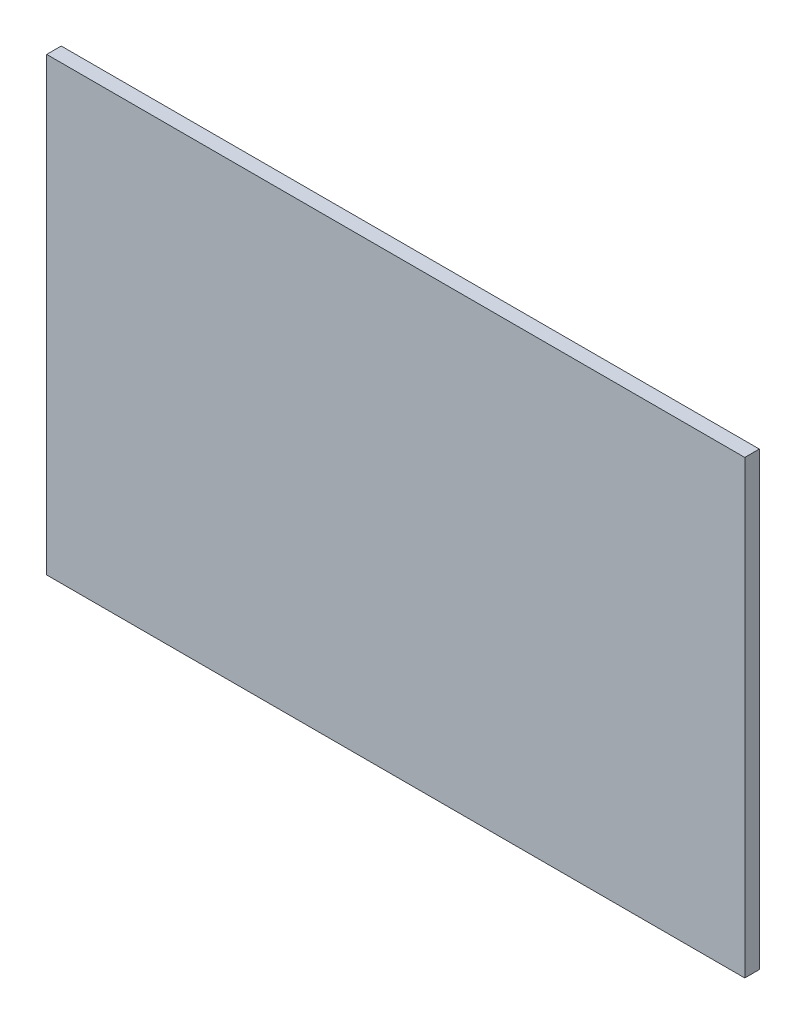
from build123d import *

# Parameters (mm, degrees)
SKETCH_1_W      = 96
SKETCH_1_H      = 62
EXTRUDE_1_DEPTH = 2


with BuildPart() as part:
    # ｽｹｯﾁ1 → ﾎﾞｽ - 押し出し1 (new body)
    with BuildSketch(Plane.XY):
        with Locations((5.311186132, -2.735849057)):
            Rectangle(SKETCH_1_W, SKETCH_1_H)
    extrude(amount=EXTRUDE_1_DEPTH)


solid = part.part
